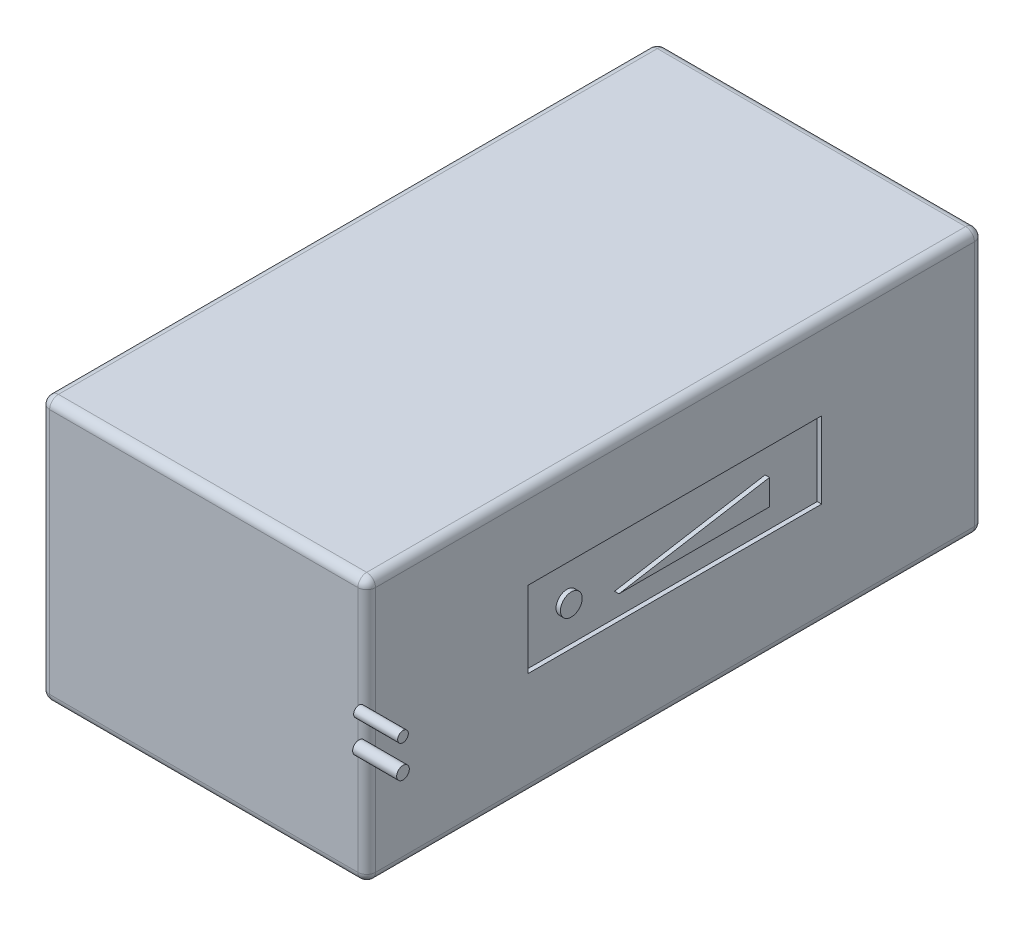
from build123d import *

# Parameters (mm, degrees)
SKETCH_1_W          = 74
SKETCH_1_H          = 140
EXTRUDE_1_DEPTH     = 60
FILLET_1_R          = 2
SKETCH_2_W          = 66.636795908
SKETCH_2_H          = 17.369780924
SKETCH_2_R          = 2.471637057
CUT_EXTRUDE_1_DEPTH = 1
SKETCH_3_R          = 1.206421208
EXTRUDE_2_DEPTH     = 10
SKETCH_3_R_2        = 1.435732572
EXTRUDE_2_2_DEPTH   = 10


with BuildPart() as part:
    # 草图1 → 凸台-拉伸1 (new body)
    with BuildSketch(Plane(origin=(0, 0, 0), x_dir=(1, 0, 0), z_dir=(0, 1, 0))):
        Rectangle(SKETCH_1_W, SKETCH_1_H)
    extrude(amount=EXTRUDE_1_DEPTH)

    # 圆角1
    fillet_1_edges = [part.edges().sort_by_distance(p)[0] for p in [
        (-37, 60, 0),
        (0, 60, 70),
        (37, 60, 0),
        (0, 0, 70),
        (-37, 0, 0),
        (0, 0, -70),
        (37, 0, 0),
        (0, 60, -70),
        (37, 30, 70),
        (-37, 30, 70),
        (-37, 30, -70),
        (37, 30, -70),
    ]]
    fillet(fillet_1_edges, radius=FILLET_1_R)

    # 草图2 → 切除-拉伸1 (cut)
    with BuildSketch(Plane(origin=(37, 0, 0), x_dir=(0, 0, -1), z_dir=(1, 0, 0))):
        with Locations((0, 32.447560039)):
            Rectangle(SKETCH_2_W, SKETCH_2_H)
        with Locations((-23.528157797, 32.447560039)):
            Circle(SKETCH_2_R, mode=Mode.SUBTRACT)
        Polygon((-12.709007388, 29.134785602), (21.475365506, 29.134785602), (21.475365506, 34.919197096), align=None, mode=Mode.SUBTRACT)
    extrude(amount=-CUT_EXTRUDE_1_DEPTH, mode=Mode.SUBTRACT)


with BuildPart() as body_2:
    # 草图3 → 凸台-拉伸2 (new body)
    with BuildSketch(Plane(origin=(37, 0, 0), x_dir=(0, 0, -1), z_dir=(1, 0, 0))):
        with Locations((-71.755652282, 35.577224789)):
            Circle(SKETCH_3_R)
    extrude(amount=EXTRUDE_2_DEPTH)


with BuildPart() as body_3:
    # 草图3 → Extrude 2 2 (new body)
    with BuildSketch(Plane(origin=(37, 0, 0), x_dir=(0, 0, -1), z_dir=(1, 0, 0))):
        with Locations((-71.755652282, 28.481459221)):
            Circle(SKETCH_3_R_2)
    extrude(amount=EXTRUDE_2_2_DEPTH)


solid = Compound([part.part, body_2.part, body_3.part])
